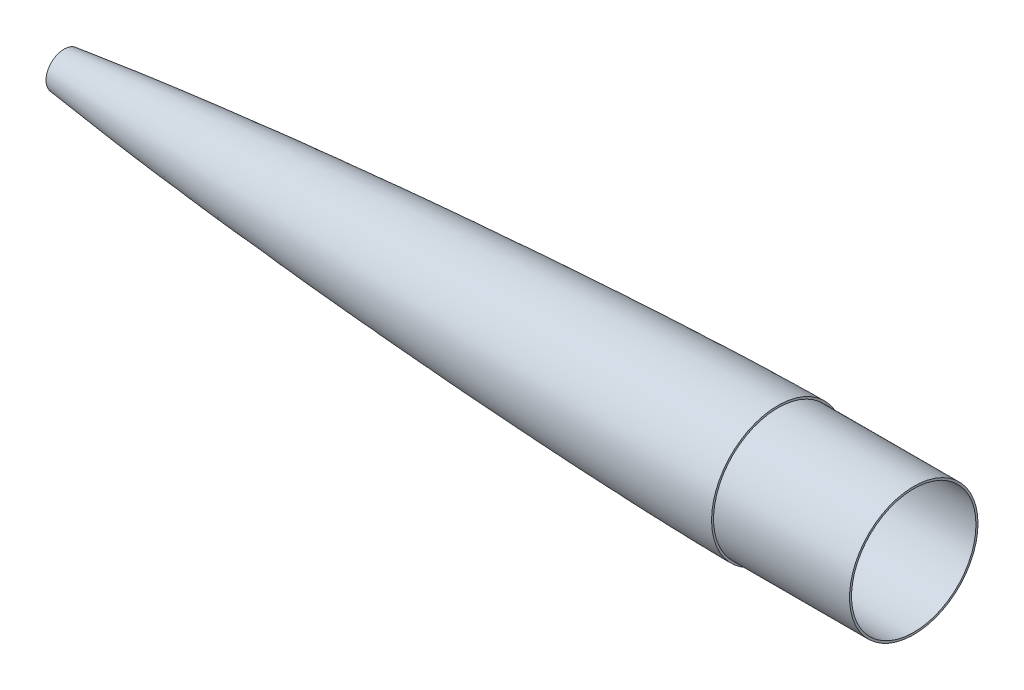
from build123d import *

# Parameters (mm, degrees)
SKETCH2_R                = 48.018506502
SKETCH2_R_2              = 46.494506502
BOSS_EXTRUDE1_DEPTH      = 101.6
BOSS_EXTRUDE1_DEPTH_BACK = 25.4


with BuildPart() as part:
    # Sketch1 → Revolve1 (revolve)
    with BuildSketch(Plane.XY):
        with BuildLine():
            add(Edge.make_bspline(
                [(76.2, 13.484253633), (80.541051361, 14.042240397), (94.160445602, 15.752086645), (117.07910842, 18.443077896), (149.319983258, 21.900765224), (186.540620523, 25.541365484), (223.788346525, 28.892582721), (261.057875937, 31.9908904), (298.345861542, 34.85826765), (335.64990165, 37.508218109), (372.968338264, 39.947038684), (410.299941718, 42.17527884), (447.643848849, 44.187159503), (484.999447818, 45.969575774), (517.695494354, 47.307189589), (545.72762747, 48.2681791), (568.326311807, 48.896405146), (583.534683102, 49.234051112), (596.024563936, 49.439736112), (603.840948359, 49.519860454), (607.749290513, 49.542506502), (609.703485351, 49.542506502)],
                knots=[0.126579539, 0.126579539, 0.126579539, 0.126579539, 0.126579539, 0.155163745, 0.216224183, 0.277284623, 0.338345063, 0.399405504, 0.460465944, 0.521526385, 0.582586825, 0.643647266, 0.704707706, 0.765768146, 0.826828587, 0.887889028, 0.918419248, 0.948949468, 0.974474734, 0.987237367, 1, 1, 1, 1, 1], degree=4))
            Line((76.2, 13.484253633), (76.2, 11.947708493))
            add(Edge.make_bspline(
                [(76.2, 11.947708493), (82.378156316, 12.742501267), (94.884009221, 14.2918782), (113.732070411, 16.484399436), (132.736266708, 18.573495042), (158.091363842, 21.221794503), (189.8102718, 24.306192238), (227.902611515, 27.708549317), (266.018568132, 30.848827321), (304.154176988, 33.749573708), (342.306680767, 36.424163266), (393.196574129, 39.695685424), (438.931967907, 42.23963824), (478.317604938, 44.104180436), (503.789466008, 45.214005638), (534.451677838, 46.389555069), (565.117800073, 47.318828106), (590.605905239, 47.841312968), (603.336130237, 48.018506502), (609.703485351, 48.018506502)],
                knots=[0.126259456, 0.126259456, 0.126259456, 0.126259456, 0.156794105, 0.188023953, 0.219253801, 0.250483649, 0.312943345, 0.375403041, 0.437862737, 0.500322433, 0.562782129, 0.625241824, 0.750161216, 0.787196768, 0.818426616, 0.875080608, 0.937540304, 0.968770152, 1, 1, 1, 1], degree=3))
            Line((609.703485351, 48.018506502), (609.703485351, 49.542506502))
        make_face()
    revolve(axis=Axis((0, 0, 0), (1, 0, 0)))

    # Sketch2 → Boss-Extrude1 (add, two sides)
    with BuildSketch(Plane(origin=(609.703485351, 0, 0), x_dir=(0, 0, -1), z_dir=(1, 0, 0))) as boss_extrude1_sk:
        Circle(SKETCH2_R)
        Circle(SKETCH2_R_2, mode=Mode.SUBTRACT)
    extrude(amount=BOSS_EXTRUDE1_DEPTH)
    extrude(boss_extrude1_sk.sketch, amount=-BOSS_EXTRUDE1_DEPTH_BACK)


solid = part.part
